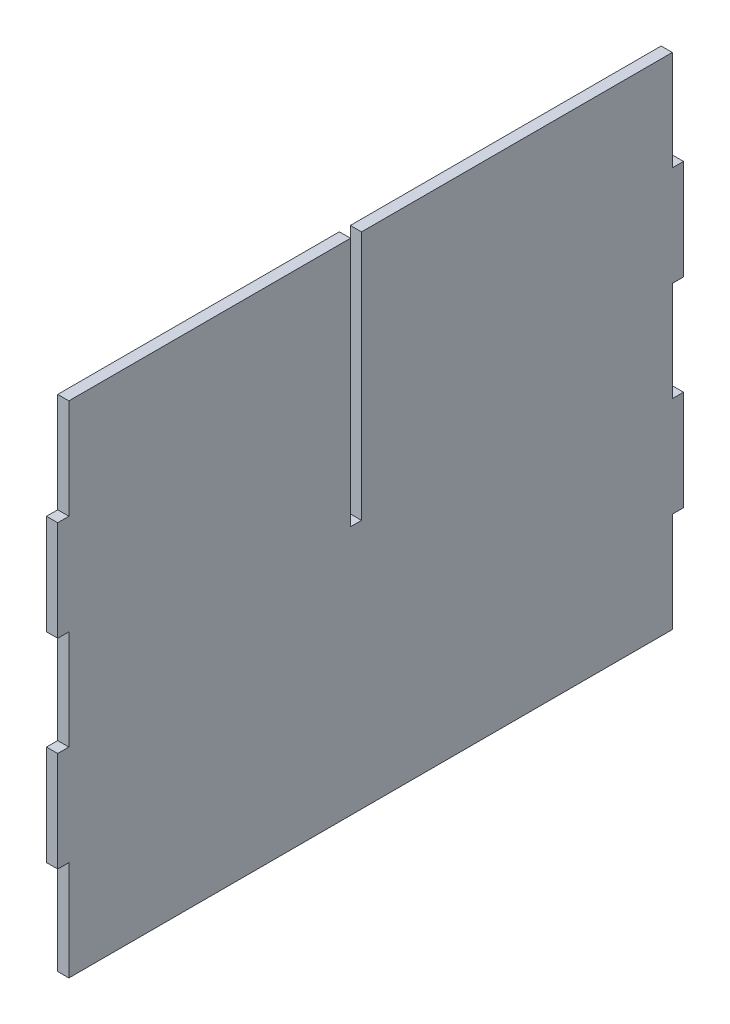
from build123d import *

# Parameters (mm, degrees)
BOSS_EXTRUDE2_DEPTH = 5.4
BOSS_EXTRUDE3_DEPTH = 5.4


with BuildPart() as part:
    # Sketch1 → Boss-Extrude2 (new body)
    with BuildSketch(Plane(origin=(0, 0, 0), x_dir=(0, 0, -1), z_dir=(1, 0, 0))):
        Polygon((142.9875, 130), (-7.0375, 130), (-7.0375, 9.3375), (-12.4375, 9.3375), (-12.4375, 130), (-148.3875, 130), (-148.3875, 81.735), (-153.7875, 81.735), (-153.7875, 33.47), (-148.3875, 33.47), (-148.3875, -14.795), (-153.7875, -14.795), (-153.7875, -63.06), (-148.3875, -63.06), (-148.3875, -111.325), (142.9875, -111.325), (142.9875, -63.06), (148.3875, -63.06), (148.3875, -14.795), (142.9875, -14.795), (142.9875, 33.47), (148.3875, 33.47), (148.3875, 81.735), (142.9875, 81.735), align=None)
    extrude(amount=BOSS_EXTRUDE2_DEPTH)

    # Sketch2 → Boss-Extrude3 (add)
    with BuildSketch(Plane(origin=(5.4, 0, 0), x_dir=(0, 0, -1), z_dir=(1, 0, 0))):
        Polygon((-148.42814, -111.36564), (143.02814, -111.36564), (143.02814, -63.10064), (148.42814, -63.10064), (148.42814, -14.75436), (143.02814, -14.75436), (143.02814, 33.42936), (148.42814, 33.42936), (148.42814, 81.77564), (143.02814, 81.77564), (143.02814, 130.04064), (-7.07814, 130.04064), (-7.07814, 9.37814), (-12.39686, 9.37814), (-12.39686, 130.04064), (-148.42814, 130.04064), (-148.42814, 81.77564), (-153.82814, 81.77564), (-153.82814, 33.42936), (-148.42814, 33.42936), (-148.42814, -14.75436), (-153.82814, -14.75436), (-153.82814, -63.10064), (-148.42814, -63.10064), align=None)
    extrude(amount=-BOSS_EXTRUDE3_DEPTH)


solid = part.part
